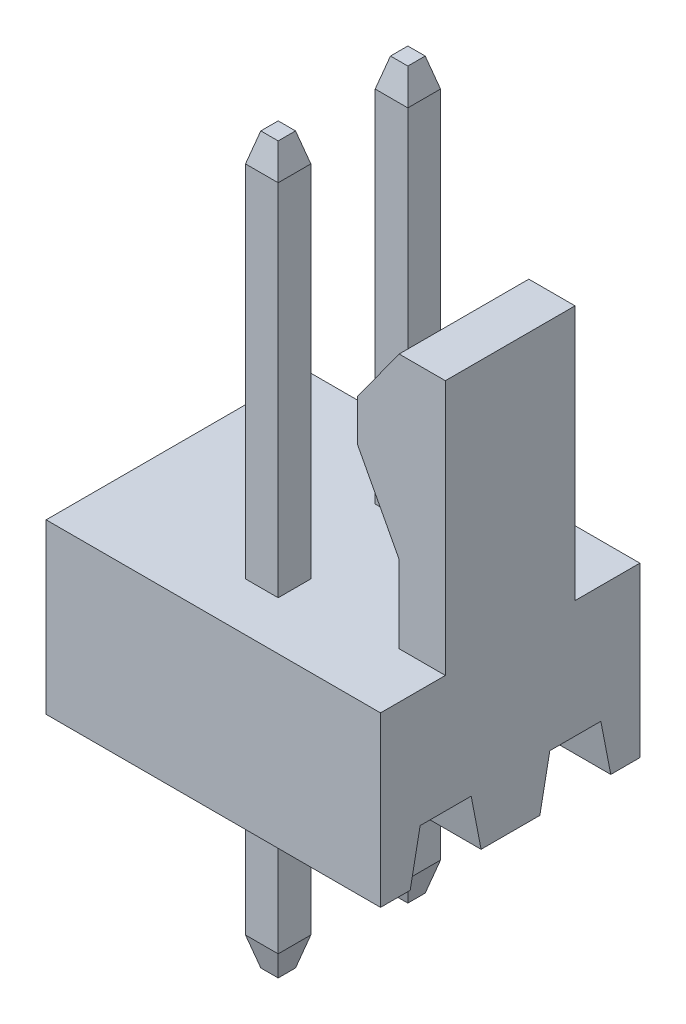
from build123d import *

# Parameters (mm, degrees)
SALIENTE_EXTRUIR1_DEPTH      = 5.08
CROQUIS2_W                   = 1.27
CROQUIS2_H                   = 5
CORTAR_EXTRUIR1_DEPTH        = 5.08
CORTAR_EXTRUIR1_DEPTH_BACK   = 5.08
CROQUIS4_W                   = 0.64
CROQUIS4_H                   = 0.64
CORTAR_EXTRUIR2_DEPTH        = 5.08
CORTAR_EXTRUIR3_DEPTH        = 15.08
CROQUIS6_W                   = 0.64
CROQUIS6_H                   = 0.64
SALIENTE_EXTRUIR2_DEPTH      = 7.6
SALIENTE_EXTRUIR2_DEPTH_BACK = 6.6
CHAFL_N1_SIZE                = 0.15
CHAFL_N1_SIZE2               = 0.559807621
CHAFL_N1_PART_2_SIZE         = 0.15
CHAFL_N1_PART_2_SIZE2        = 0.559807621
CHAFL_N2_SIZE                = 0.15
CHAFL_N2_SIZE2               = 0.559807621
CHAFL_N2_PART_2_SIZE         = 0.15
CHAFL_N2_PART_2_SIZE2        = 0.559807621
CROQUIS7_R                   = 0.108736381
CORTAR_EXTRUIR4_DEPTH        = 0.1


with BuildPart() as part:
    # Croquis1 → Saliente-Extruir1 (new body)
    with BuildSketch(Plane.XY):
        Polygon((0, 0), (6.55, 0), (6.55, 8.3), (5.64478846, 8.3), (4.827789026, 7.170813791), (4.827789026, 6.360456628), (5.64478846, 4.814385239), (5.64478846, 3.3), (0, 3.3), align=None)
    extrude(amount=SALIENTE_EXTRUIR1_DEPTH)

    # Croquis2 → Cortar-Extruir1 (cut, two sides)
    with BuildSketch(Plane.ZY.offset(-5.64478846)) as cortar_extruir1_sk:
        with Locations((0.635, 5.8)):
            Rectangle(CROQUIS2_W, CROQUIS2_H)
        with Locations((4.445, 5.8)):
            Rectangle(CROQUIS2_W, CROQUIS2_H)
    extrude(amount=CORTAR_EXTRUIR1_DEPTH, mode=Mode.SUBTRACT)
    extrude(cortar_extruir1_sk.sketch, amount=-CORTAR_EXTRUIR1_DEPTH_BACK, mode=Mode.SUBTRACT)

    # Croquis4 → Cortar-Extruir2 (cut)
    with BuildSketch(Plane(origin=(0, 3.3, 0), x_dir=(1, 0, 0), z_dir=(0, 1, 0))):
        with Locations((3.275, -1.27)):
            Rectangle(CROQUIS4_W, CROQUIS4_H)
        with Locations((3.275, -3.81)):
            Rectangle(CROQUIS4_W, CROQUIS4_H)
    extrude(amount=-CORTAR_EXTRUIR2_DEPTH, mode=Mode.SUBTRACT)

    # Croquis5 → Cortar-Extruir3 (cut)
    with BuildSketch(Plane.ZY):
        Polygon((1.264438254, 1), (1.764438254, 1), (1.958818564, 0), (0.570057945, 0), (0.764438254, 1), align=None)
        Polygon((3.304438254, 1), (3.110057945, 0), (4.498818564, 0), (4.304438254, 1), (3.804438254, 1), align=None)
    extrude(amount=-CORTAR_EXTRUIR3_DEPTH, mode=Mode.SUBTRACT)

    # Croquis6 → Saliente-Extruir2 (add, two sides)
    with BuildSketch(Plane(origin=(0, 3.3, 0), x_dir=(1, 0, 0), z_dir=(0, 1, 0))) as saliente_extruir2_sk:
        with Locations((3.275, -1.27)):
            Rectangle(CROQUIS6_W, CROQUIS6_H)
        with Locations((3.275, -3.81)):
            Rectangle(CROQUIS6_W, CROQUIS6_H)
    extrude(amount=SALIENTE_EXTRUIR2_DEPTH)
    extrude(saliente_extruir2_sk.sketch, amount=-SALIENTE_EXTRUIR2_DEPTH_BACK)

    # Chaflán1
    chafl_n1_edges = [part.edges().sort_by_distance(p)[0] for p in [
        (3.595, 10.9, 1.27),
        (3.275, 10.9, 0.95),
        (2.955, 10.9, 1.27),
        (3.275, 10.9, 1.59),
    ]]
    chafl_n1_side = [part.faces().sort_by_distance(p)[0] for p in [
        (3.275, 10.9, 1.27),
    ]]
    chamfer(chafl_n1_edges, length=CHAFL_N1_SIZE, length2=CHAFL_N1_SIZE2, reference=chafl_n1_side[0])

    # Chaflán1 part 2
    chafl_n1_part_2_edges = [part.edges().sort_by_distance(p)[0] for p in [
        (3.595, 10.9, 3.81),
        (3.275, 10.9, 3.49),
        (2.955, 10.9, 3.81),
        (3.275, 10.9, 4.13),
    ]]
    chafl_n1_part_2_side = [part.faces().sort_by_distance(p)[0] for p in [
        (3.275, 10.9, 3.81),
    ]]
    chamfer(chafl_n1_part_2_edges, length=CHAFL_N1_PART_2_SIZE, length2=CHAFL_N1_PART_2_SIZE2, reference=chafl_n1_part_2_side[0])

    # Chaflán2
    chafl_n2_edges = [part.edges().sort_by_distance(p)[0] for p in [
        (3.595, -3.3, 1.27),
        (3.275, -3.3, 1.59),
        (2.955, -3.3, 1.27),
        (3.275, -3.3, 0.95),
    ]]
    chafl_n2_side = [part.faces().sort_by_distance(p)[0] for p in [
        (3.275, -3.3, 1.27),
    ]]
    chamfer(chafl_n2_edges, length=CHAFL_N2_SIZE, length2=CHAFL_N2_SIZE2, reference=chafl_n2_side[0])

    # Chaflán2 part 2
    chafl_n2_part_2_edges = [part.edges().sort_by_distance(p)[0] for p in [
        (3.595, -3.3, 3.81),
        (3.275, -3.3, 4.13),
        (2.955, -3.3, 3.81),
        (3.275, -3.3, 3.49),
    ]]
    chafl_n2_part_2_side = [part.faces().sort_by_distance(p)[0] for p in [
        (3.275, -3.3, 3.81),
    ]]
    chamfer(chafl_n2_part_2_edges, length=CHAFL_N2_PART_2_SIZE, length2=CHAFL_N2_PART_2_SIZE2, reference=chafl_n2_part_2_side[0])

    # Croquis7 → Cortar-Extruir4 (cut)
    with BuildSketch(Plane.XZ.offset(3.3)):
        with Locations((3.275, 3.81)):
            Circle(CROQUIS7_R)
    extrude(amount=-CORTAR_EXTRUIR4_DEPTH, mode=Mode.SUBTRACT)


solid = part.part
